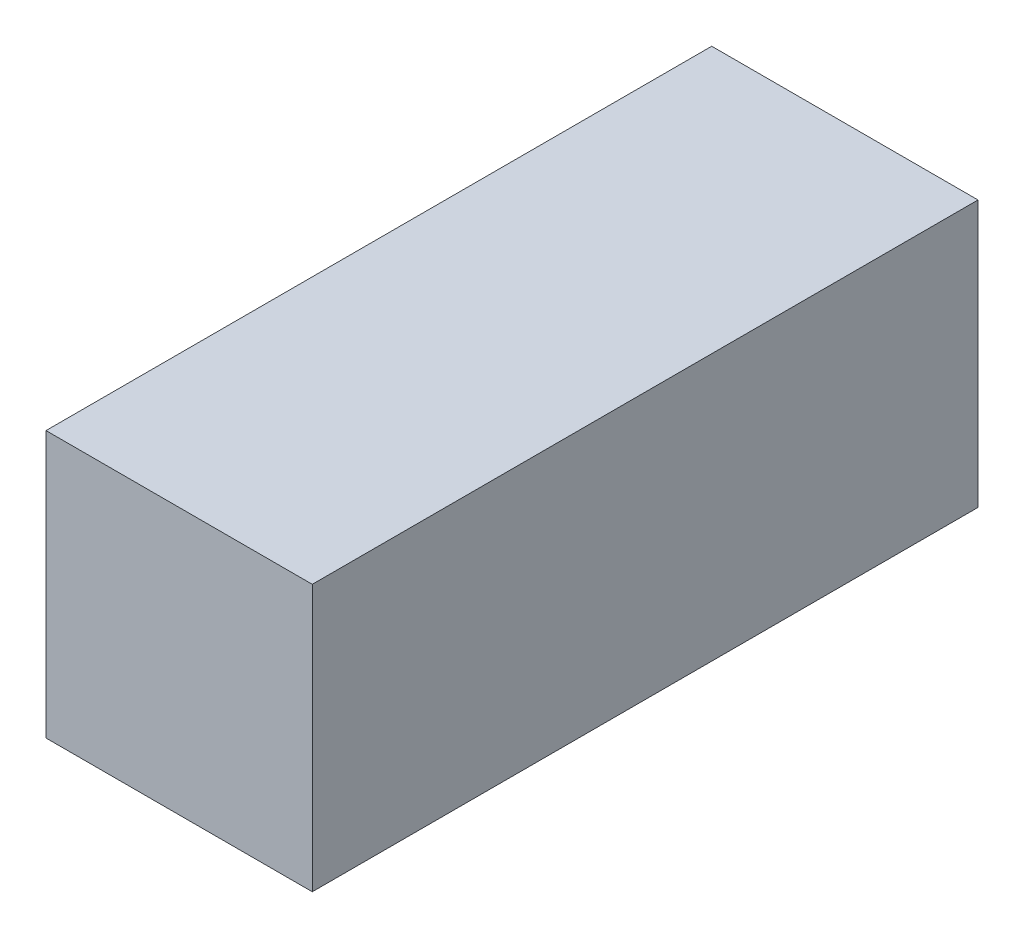
from build123d import *

# Parameters (mm, degrees)
SKETCH1_W           = 40
SKETCH1_H           = 100
BOSS_EXTRUDE2_DEPTH = 40


with BuildPart() as part:
    # Sketch1 → Boss-Extrude2 (new body)
    with BuildSketch(Plane(origin=(0, 0, 0), x_dir=(1, 0, 0), z_dir=(0, 1, 0))):
        with Locations((20, 50)):
            Rectangle(SKETCH1_W, SKETCH1_H)
    extrude(amount=BOSS_EXTRUDE2_DEPTH)


solid = part.part
